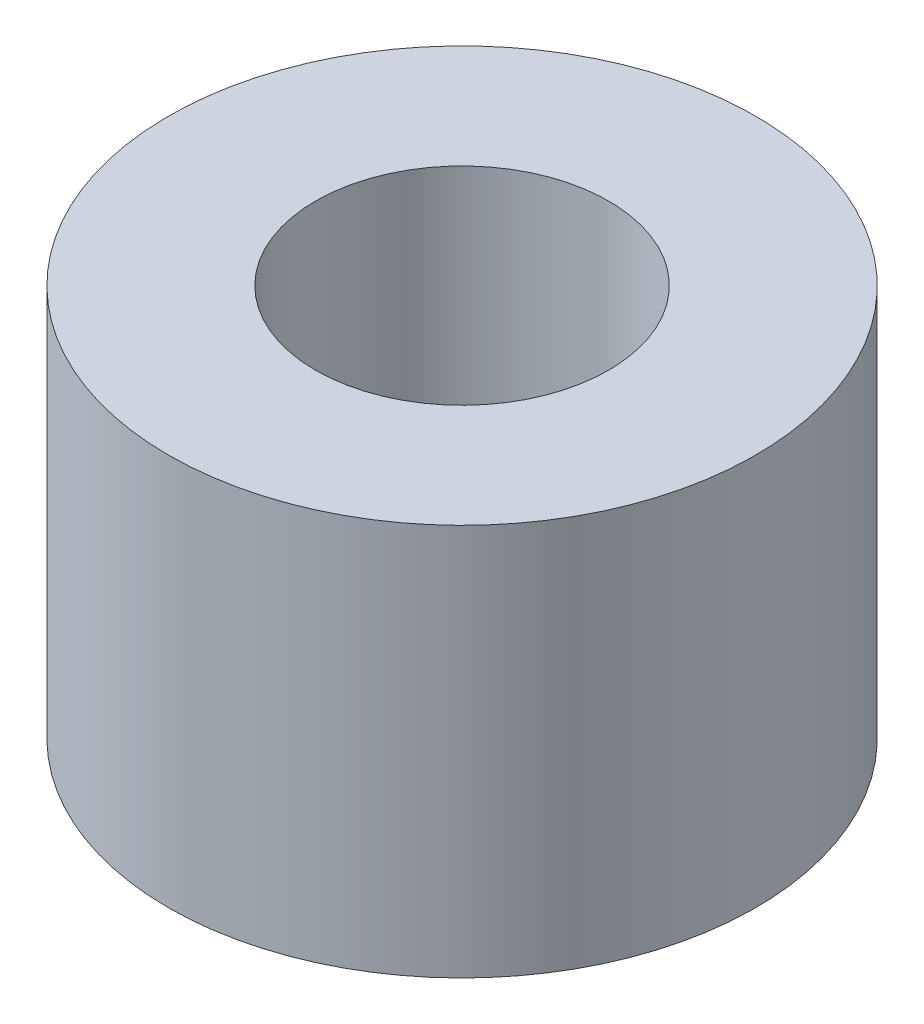
from build123d import *

# Parameters (mm, degrees)
CROQUIS1_R              = 2.99560024
CROQUIS1_R_2            = 1.495598695
SALIENTE_EXTRUIR1_DEPTH = 4


with BuildPart() as part:
    # Croquis1 → Saliente-Extruir1 (new body)
    with BuildSketch(Plane(origin=(0, 0, 0), x_dir=(1, 0, 0), z_dir=(0, 1, 0))):
        with Locations((0, 0.123865495)):
            Circle(CROQUIS1_R)
        with Locations((1.32e-07, 0.123865455)):
            Circle(CROQUIS1_R_2, mode=Mode.SUBTRACT)
    extrude(amount=SALIENTE_EXTRUIR1_DEPTH)


solid = part.part
